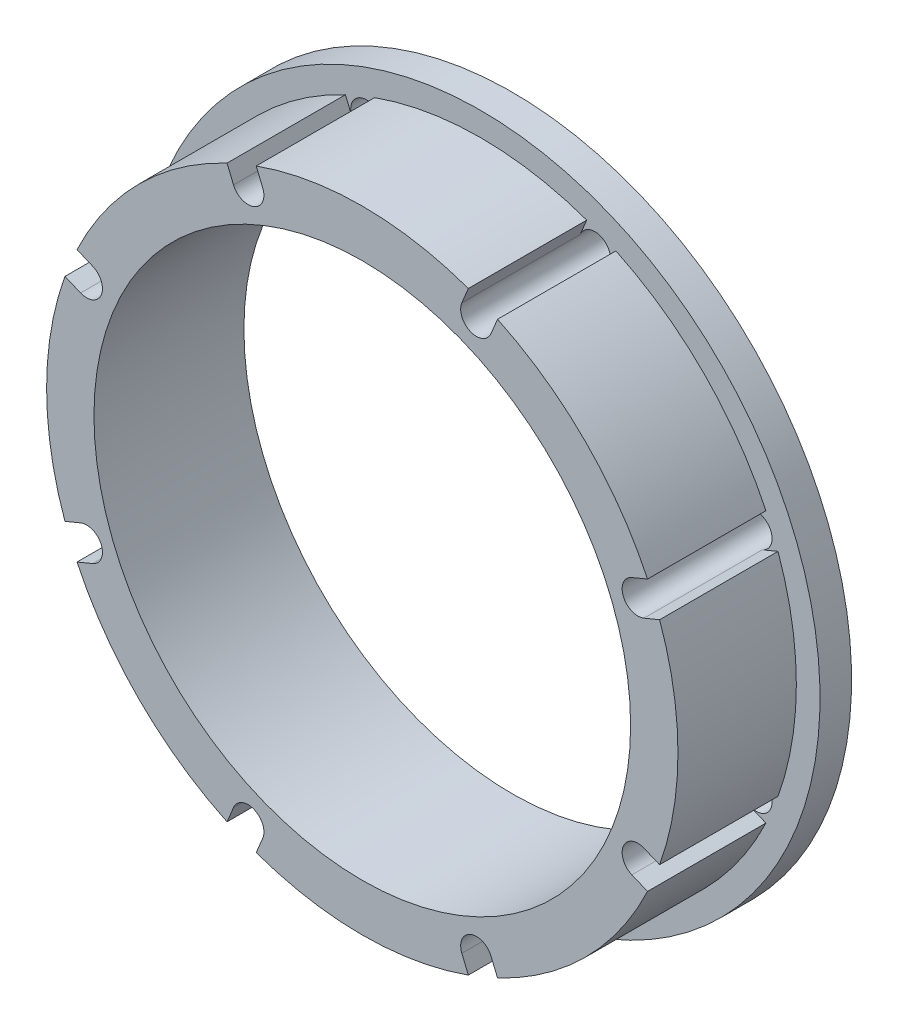
from build123d import *

# Parameters (mm, degrees)
SKIZZE1_R                                            = 20
SKIZZE1_R_2                                          = 17
AUFSATZ_LINEAR_AUSTRAGEN1_DEPTH                      = 0.5
AUFSATZ_LINEAR_AUSTRAGEN1_DEPTH_BACK                 = 7
SKIZZE7_R                                            = 21.5
SKIZZE7_R_2                                          = 17
AUFSATZ_LINEAR_AUSTRAGEN2_DEPTH                      = 2
FORMSENKUNG_F_R_M3_SENKSCHRAUBE_MIT_INNE_D           = 1.6
FORMSENKUNG_F_R_M3_SENKSCHRAUBE_MIT_INNE_DEPTH       = 13.5
FORMSENKUNG_F_R_M3_SENKSCHRAUBE_MIT_INNE_CSINK_D     = 3
FORMSENKUNG_F_R_M3_SENKSCHRAUBE_MIT_INNE_CSINK_ANGLE = 90
FORMSENKUNG_F_R_M3_SENKSCHRAUBE_MIT_INNE_TIP         = 0.480688495
SCHNITT_LINEAR_AUSTRAGEN1_DEPTH                      = 7.5
SKIZZE10_3_R                                         = 0.8
SCHNITT_LINEAR_AUSTRAGEN3_DEPTH                      = 32.855140872


with BuildPart() as part:
    # Skizze1 → Aufsatz-Linear austragen1 (new, two sides)
    with BuildSketch(Plane.XY) as aufsatz_linear_austragen1_sk:
        with Locations(Location((0, 0, 0), (0, 0, 180))):
            Circle(SKIZZE1_R)
        with Locations(Location((0, 0, 0), (0, 0, 180))):
            Circle(SKIZZE1_R_2, mode=Mode.SUBTRACT)
    extrude(amount=AUFSATZ_LINEAR_AUSTRAGEN1_DEPTH)
    extrude(aufsatz_linear_austragen1_sk.sketch, amount=-AUFSATZ_LINEAR_AUSTRAGEN1_DEPTH_BACK)

    # Skizze7 → Aufsatz-Linear austragen2 (add)
    with BuildSketch(Plane(origin=(0, 0, -7), x_dir=(-1, 0, 0), z_dir=(0, 0, -1))):
        Circle(SKIZZE7_R)
        Circle(SKIZZE7_R_2, mode=Mode.SUBTRACT)
    extrude(amount=AUFSATZ_LINEAR_AUSTRAGEN2_DEPTH)

    # Formsenkung f_r M3 Senkschraube mit Inne
    with Locations(Plane(origin=(0, 0, -9), x_dir=(-1, 0, 0), z_dir=(0, 0, -1))):
        with Locations((7.232716872, 17.461323164), (17.461323164, 7.232716872), (17.461323164, -7.232716872), (7.232716872, -17.461323164), (-7.232716872, -17.461323164), (-17.461323164, -7.232716872), (-17.461323164, 7.232716872), (-7.232716872, 17.461323164), (0, 0)):
            CounterSinkHole(FORMSENKUNG_F_R_M3_SENKSCHRAUBE_MIT_INNE_D / 2, FORMSENKUNG_F_R_M3_SENKSCHRAUBE_MIT_INNE_CSINK_D / 2, depth=FORMSENKUNG_F_R_M3_SENKSCHRAUBE_MIT_INNE_DEPTH, counter_sink_angle=FORMSENKUNG_F_R_M3_SENKSCHRAUBE_MIT_INNE_CSINK_ANGLE)
            with Locations((0, 0, -(FORMSENKUNG_F_R_M3_SENKSCHRAUBE_MIT_INNE_DEPTH + FORMSENKUNG_F_R_M3_SENKSCHRAUBE_MIT_INNE_TIP / 2))):  # 118° drill point
                Cone(0, FORMSENKUNG_F_R_M3_SENKSCHRAUBE_MIT_INNE_D / 2, FORMSENKUNG_F_R_M3_SENKSCHRAUBE_MIT_INNE_TIP, mode=Mode.SUBTRACT)

    # Skizze10 → Schnitt-Linear austragen1 (cut)
    with BuildSketch(Plane.XY.offset(0.5)):
        with BuildLine():
            Line((-8.156596404, 17.078639732), (-8.567975107, 18.071795776))
            ThreePointArc((-8.567975107, 18.071795776), (-7.653668647, 18.47759065), (-6.720216042, 18.837162641))
            Line((-6.720216042, 18.837162641), (-6.308837339, 17.844006597))
            ThreePointArc((-6.308837339, 17.844006597), (-6.850033439, 16.537443632), (-8.156596404, 17.078639732))
        make_face()
        with BuildLine():
            Line((6.308837339, 17.844006597), (6.720216042, 18.837162641))
            ThreePointArc((6.720216042, 18.837162641), (7.653668647, 18.47759065), (8.567975107, 18.071795776))
            Line((8.567975107, 18.071795776), (8.156596404, 17.078639732))
            ThreePointArc((8.156596404, 17.078639732), (6.850033439, 16.537443632), (6.308837339, 17.844006597))
        make_face()
        with BuildLine():
            Line((17.078639732, 8.156596404), (18.071795776, 8.567975107))
            ThreePointArc((18.071795776, 8.567975107), (18.47759065, 7.653668647), (18.837162641, 6.720216042))
            Line((18.837162641, 6.720216042), (17.844006597, 6.308837339))
            ThreePointArc((17.844006597, 6.308837339), (16.537443632, 6.850033439), (17.078639732, 8.156596404))
        make_face()
        with BuildLine():
            Line((17.844006597, -6.308837339), (18.837162641, -6.720216042))
            ThreePointArc((18.837162641, -6.720216042), (18.47759065, -7.653668647), (18.071795776, -8.567975107))
            Line((18.071795776, -8.567975107), (17.078639732, -8.156596404))
            ThreePointArc((17.078639732, -8.156596404), (16.537443632, -6.850033439), (17.844006597, -6.308837339))
        make_face()
        with BuildLine():
            Line((8.156596404, -17.078639732), (8.567975107, -18.071795776))
            ThreePointArc((8.567975107, -18.071795776), (7.653668647, -18.47759065), (6.720216042, -18.837162641))
            Line((6.720216042, -18.837162641), (6.308837339, -17.844006597))
            ThreePointArc((6.308837339, -17.844006597), (6.850033439, -16.537443632), (8.156596404, -17.078639732))
        make_face()
        with BuildLine():
            Line((-6.308837339, -17.844006597), (-6.720216042, -18.837162641))
            ThreePointArc((-6.720216042, -18.837162641), (-7.653668647, -18.47759065), (-8.567975107, -18.071795776))
            Line((-8.567975107, -18.071795776), (-8.156596404, -17.078639732))
            ThreePointArc((-8.156596404, -17.078639732), (-6.850033439, -16.537443632), (-6.308837339, -17.844006597))
        make_face()
        with BuildLine():
            Line((-17.078639732, -8.156596404), (-18.071795776, -8.567975107))
            ThreePointArc((-18.071795776, -8.567975107), (-18.47759065, -7.653668647), (-18.837162641, -6.720216042))
            Line((-18.837162641, -6.720216042), (-17.844006597, -6.308837339))
            ThreePointArc((-17.844006597, -6.308837339), (-16.537443632, -6.850033439), (-17.078639732, -8.156596404))
        make_face()
        with BuildLine():
            Line((-17.844006597, 6.308837339), (-18.837162641, 6.720216042))
            ThreePointArc((-18.837162641, 6.720216042), (-18.47759065, 7.653668647), (-18.071795776, 8.567975107))
            Line((-18.071795776, 8.567975107), (-17.078639732, 8.156596404))
            ThreePointArc((-17.078639732, 8.156596404), (-16.537443632, 6.850033439), (-17.844006597, 6.308837339))
        make_face()
    extrude(amount=-SCHNITT_LINEAR_AUSTRAGEN1_DEPTH, mode=Mode.SUBTRACT)

    # Skizze10_3 → Schnitt-Linear austragen3 (cut, through all)
    with BuildSketch(Plane.XY.offset(0.5)):
        with BuildLine():
            ThreePointArc((-8.156596404, 17.078639732), (-7.615400304, 18.385202697), (-6.308837339, 17.844006597))
            ThreePointArc((-6.308837339, 17.844006597), (-6.850033439, 16.537443632), (-8.156596404, 17.078639732))
        make_face()
        with Locations((-7.232716872, 17.461323164)):
            Circle(SKIZZE10_3_R, mode=Mode.SUBTRACT)
        with BuildLine():
            ThreePointArc((-17.844006597, 6.308837339), (-18.385202697, 7.615400304), (-17.078639732, 8.156596404))
            ThreePointArc((-17.078639732, 8.156596404), (-16.537443632, 6.850033439), (-17.844006597, 6.308837339))
        make_face()
        with Locations((-17.461323164, 7.232716872)):
            Circle(SKIZZE10_3_R, mode=Mode.SUBTRACT)
        with BuildLine():
            ThreePointArc((-17.078639732, -8.156596404), (-18.385202697, -7.615400304), (-17.844006597, -6.308837339))
            ThreePointArc((-17.844006597, -6.308837339), (-16.537443632, -6.850033439), (-17.078639732, -8.156596404))
        make_face()
        with Locations((-17.461323164, -7.232716872)):
            Circle(SKIZZE10_3_R, mode=Mode.SUBTRACT)
        with BuildLine():
            ThreePointArc((-6.308837339, -17.844006597), (-7.615400304, -18.385202697), (-8.156596404, -17.078639732))
            ThreePointArc((-8.156596404, -17.078639732), (-6.850033439, -16.537443632), (-6.308837339, -17.844006597))
        make_face()
        with Locations((-7.232716872, -17.461323164)):
            Circle(SKIZZE10_3_R, mode=Mode.SUBTRACT)
        with BuildLine():
            ThreePointArc((8.156596404, -17.078639732), (7.615400304, -18.385202697), (6.308837339, -17.844006597))
            ThreePointArc((6.308837339, -17.844006597), (6.850033439, -16.537443632), (8.156596404, -17.078639732))
        make_face()
        with Locations((7.232716872, -17.461323164)):
            Circle(SKIZZE10_3_R, mode=Mode.SUBTRACT)
        with BuildLine():
            ThreePointArc((17.844006597, -6.308837339), (18.385202697, -7.615400304), (17.078639732, -8.156596404))
            ThreePointArc((17.078639732, -8.156596404), (16.537443632, -6.850033439), (17.844006597, -6.308837339))
        make_face()
        with Locations((17.461323164, -7.232716872)):
            Circle(SKIZZE10_3_R, mode=Mode.SUBTRACT)
        with BuildLine():
            ThreePointArc((6.308837339, 17.844006597), (7.615400304, 18.385202697), (8.156596404, 17.078639732))
            ThreePointArc((8.156596404, 17.078639732), (6.850033439, 16.537443632), (6.308837339, 17.844006597))
        make_face()
        with Locations((7.232716872, 17.461323164)):
            Circle(SKIZZE10_3_R, mode=Mode.SUBTRACT)
        with BuildLine():
            ThreePointArc((17.078639732, 8.156596404), (18.385202697, 7.615400304), (17.844006597, 6.308837339))
            ThreePointArc((17.844006597, 6.308837339), (16.537443632, 6.850033439), (17.078639732, 8.156596404))
        make_face()
        with Locations((17.461323164, 7.232716872)):
            Circle(SKIZZE10_3_R, mode=Mode.SUBTRACT)
        with BuildLine():
            ThreePointArc((-7.615400304, 18.385202697), (-8.156596404, 17.844006597), (-8.156596404, 17.078639732))
            ThreePointArc((-8.156596404, 17.078639732), (-7.615400304, 16.537443632), (-6.850033439, 16.537443632))
            Line((-6.850033439, 16.537443632), (-6.926570126, 16.722219538))
            ThreePointArc((-6.926570126, 16.722219538), (-7.971820498, 17.155176419), (-7.538863618, 18.20042679))
            Line((-7.538863618, 18.20042679), (-7.615400304, 18.385202697))
        make_face()
        with BuildLine():
            Line((-6.926570126, 16.722219538), (-6.850033439, 16.537443632))
            ThreePointArc((-6.850033439, 16.537443632), (-6.308837339, 17.078639732), (-6.308837339, 17.844006597))
            ThreePointArc((-6.308837339, 17.844006597), (-6.850033439, 18.385202697), (-7.615400304, 18.385202697))
            Line((-7.615400304, 18.385202697), (-7.538863618, 18.20042679))
            ThreePointArc((-7.538863618, 18.20042679), (-6.788260685, 18.126498854), (-6.432716872, 17.461323164))
            ThreePointArc((-6.432716872, 17.461323164), (-6.567541182, 17.016866978), (-6.926570126, 16.722219538))
        make_face()
    extrude(amount=-SCHNITT_LINEAR_AUSTRAGEN3_DEPTH, mode=Mode.SUBTRACT)


solid = part.part
